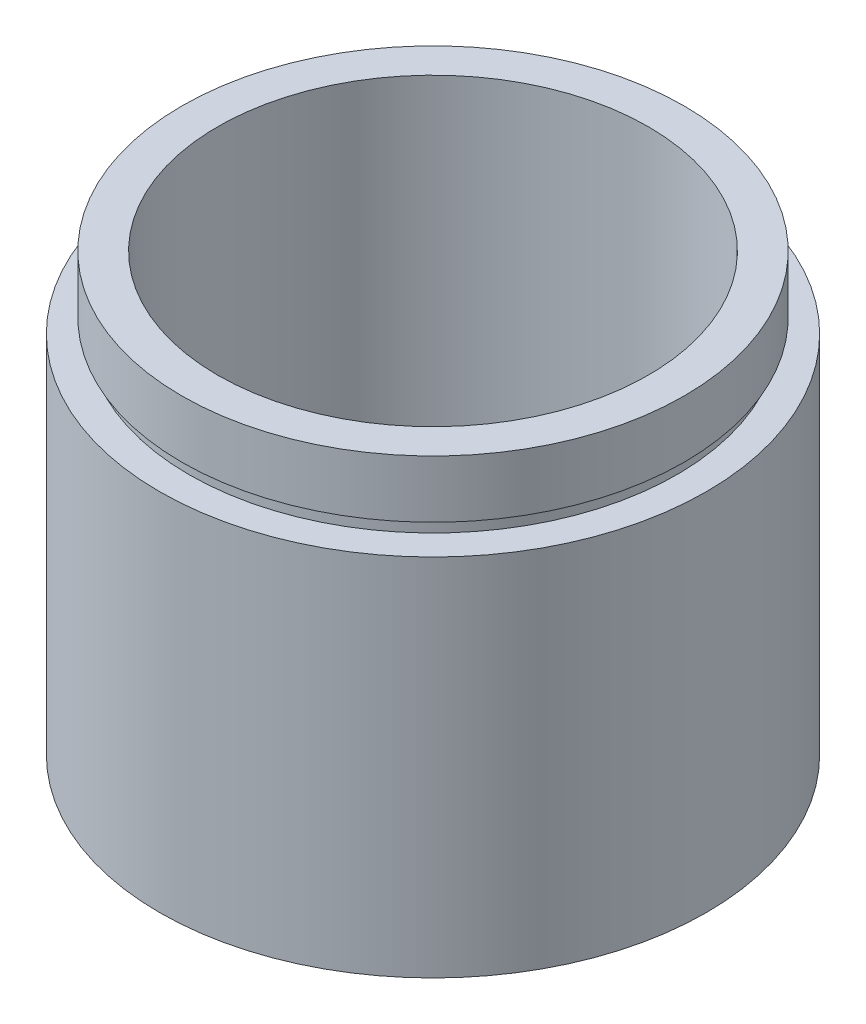
from build123d import *


with BuildPart() as part:
    # 草图1 → 旋转1 (revolve)
    with BuildSketch(Plane.XY, mode=Mode.PRIVATE) as revolve_1_sk:
        Polygon((19.05, 0), (19.05, 25.4), (17, 25.4), (17, 26.4), (17.5, 26.4), (17.5, 30.4), (15, 30.4), (15, 5.5), (17.6, 5.5), (17.6, 4.5), (17, 4.5), (17, 0), align=None)
    revolve(revolve_1_sk.sketch.rotate(Axis((0, 161.376166943, 0), (0, -1, 0)), 90), axis=Axis((0, 161.376166943, 0), (0, -1, 0)))  # turned: the seam where the file's is


solid = part.part
